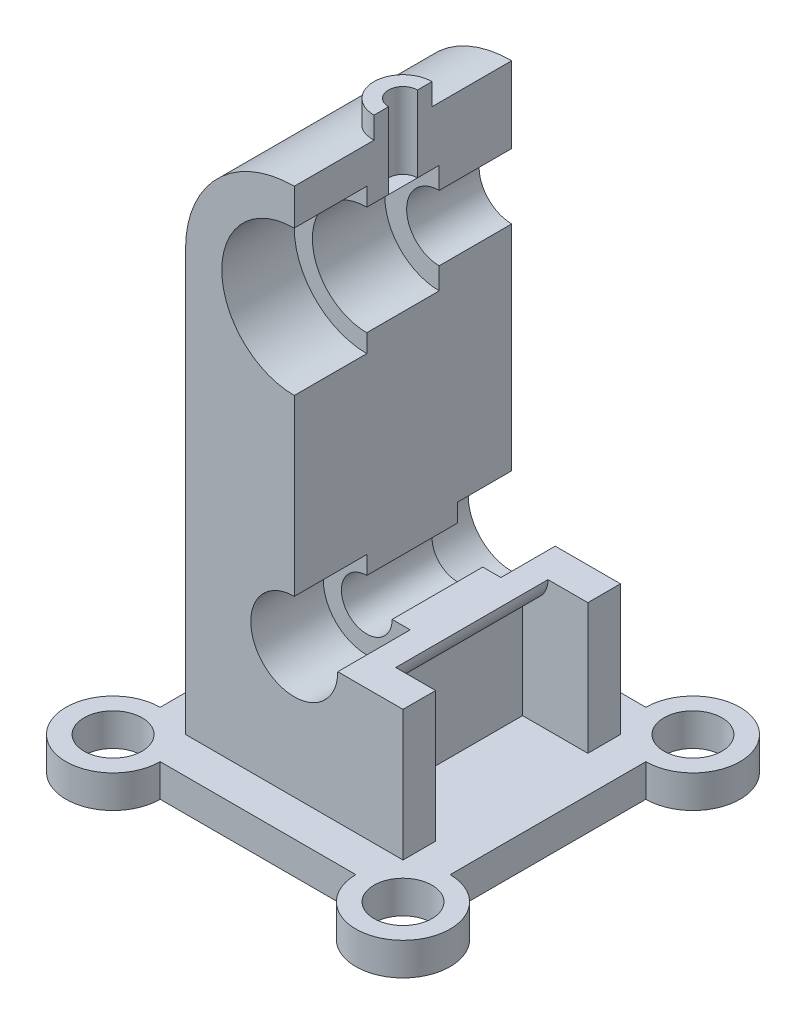
from build123d import *

# Parameters (mm, degrees)
IZIM1_W                          = 60
IZIM1_H                          = 116
Y_KSEKLIK_EKSTR_ZYON1_DEPTH      = 60
IZIM2_R                          = 8
Y_KSEKLIK_EKSTR_ZYON2_DEPTH      = 9
IZIM3_R                          = 30
Y_KSEKLIK_EKSTR_ZYON3_DEPTH      = 60
IZIM4_R                          = 20
KES_EKSTR_ZYON1_DEPTH            = 20
IZIM5_R                          = 15
KES_EKSTR_ZYON2_DEPTH            = 20
IZIM6_R                          = 9
KES_EKSTR_ZYON3_DEPTH            = 20
IZIM7_R                          = 12
KES_EKSTR_ZYON4_DEPTH            = 20
IZIM8_R                          = 7
KES_EKSTR_ZYON5_DEPTH            = 25
IZIM9_R                          = 12
KES_EKSTR_ZYON6_DEPTH            = 15
KES_EKSTR_ZYON8_DEPTH            = 30
IZIM13_W                         = 60
IZIM13_H                         = 30
KES_EKSTR_ZYON9_DEPTH            = 30
IZIM14_R                         = 8
IZIM14_R_2                       = 4
Y_KSEKLIK_EKSTR_ZYON5_DEPTH      = 6
Y_KSEKLIK_EKSTR_ZYON5_DEPTH_BACK = 15
IZIM16_W                         = 8
IZIM16_H                         = 21
KES_EKSTR_ZYON10_DEPTH           = 57
KES_EKSTR_ZYON12_DEPTH           = 15
IZIM18_W                         = 42
IZIM18_H                         = 36
KES_EKSTR_ZYON13_DEPTH           = 18
Y_KSEKLIK_EKSTR_ZYON7_DEPTH      = 42


with BuildPart() as part:
    # Çizim1 → Yükseklik-Ekstrüzyon1 (new body)
    with BuildSketch(Plane(origin=(0, 0, 0), x_dir=(0, 0, -1), z_dir=(1, 0, 0))):
        with Locations((-30, 58)):
            Rectangle(IZIM1_W, IZIM1_H)
    extrude(amount=Y_KSEKLIK_EKSTR_ZYON1_DEPTH)

    # Çizim2 → Yükseklik-Ekstrüzyon2 (add)
    with BuildSketch(Plane(origin=(0, 0, 0), x_dir=(1, 0, 0), z_dir=(0, 1, 0))):
        with BuildLine():
            Line((57, 10), (3, 10))
            ThreePointArc((3, 10), (-19.192388155, 19.192388155), (-10, -3))
            Line((-10, -3), (-10, -57))
            ThreePointArc((-10, -57), (-19.192388155, -79.192388155), (3, -70))
            Line((3, -70), (57, -70))
            ThreePointArc((57, -70), (79.192388155, -79.192388155), (70, -57))
            Line((70, -57), (70, -3))
            ThreePointArc((70, -3), (79.192388155, 19.192388155), (57, 10))
        make_face()
        with Locations((-10, 10)):
            Circle(IZIM2_R, mode=Mode.SUBTRACT)
        with Locations((-10, -70)):
            Circle(IZIM2_R, mode=Mode.SUBTRACT)
        with Locations((70, -70)):
            Circle(IZIM2_R, mode=Mode.SUBTRACT)
        with Locations((70, 10)):
            Circle(IZIM2_R, mode=Mode.SUBTRACT)
    extrude(amount=-Y_KSEKLIK_EKSTR_ZYON2_DEPTH)

    # Çizim3 → Yükseklik-Ekstrüzyon3 (add)
    with BuildSketch(Plane.XY):
        with Locations((30, 116)):
            Circle(IZIM3_R)
    extrude(amount=Y_KSEKLIK_EKSTR_ZYON3_DEPTH)

    # Çizim4 → Kes-Ekstrüzyon1 (cut)
    with BuildSketch(Plane.XY.offset(60)):
        with Locations((30, 116)):
            Circle(IZIM4_R)
    extrude(amount=-KES_EKSTR_ZYON1_DEPTH, mode=Mode.SUBTRACT)

    # Çizim5 → Kes-Ekstrüzyon2 (cut)
    with BuildSketch(Plane.XY.offset(40)):
        with Locations((30, 116)):
            Circle(IZIM5_R)
    extrude(amount=-KES_EKSTR_ZYON2_DEPTH, mode=Mode.SUBTRACT)

    # Çizim6 → Kes-Ekstrüzyon3 (cut)
    with BuildSketch(Plane.XY.offset(20)):
        with Locations((30, 116)):
            Circle(IZIM6_R)
    extrude(amount=-KES_EKSTR_ZYON3_DEPTH, mode=Mode.SUBTRACT)

    # Çizim7 → Kes-Ekstrüzyon4 (cut)
    with BuildSketch(Plane.XY.offset(60)):
        with Locations((30, 36)):
            Circle(IZIM7_R)
    extrude(amount=-KES_EKSTR_ZYON4_DEPTH, mode=Mode.SUBTRACT)

    # Çizim8 → Kes-Ekstrüzyon5 (cut)
    with BuildSketch(Plane.XY.offset(40)):
        with Locations((30, 36)):
            Circle(IZIM8_R)
    extrude(amount=-KES_EKSTR_ZYON5_DEPTH, mode=Mode.SUBTRACT)

    # Çizim9 → Kes-Ekstrüzyon6 (cut)
    with BuildSketch(Plane.XY.offset(15)):
        with Locations((30, 36)):
            Circle(IZIM9_R)
    extrude(amount=-KES_EKSTR_ZYON6_DEPTH, mode=Mode.SUBTRACT)

    # Çizim10 → Kes-Ekstrüzyon8 (cut)
    with BuildSketch(Plane(origin=(60, 0, 0), x_dir=(0, 0, -1), z_dir=(1, 0, 0))):
        Polygon((-60, 116), (-60, 36), (-51, 36), (-9, 36), (0, 36), (0, 116), align=None)
    extrude(amount=-KES_EKSTR_ZYON8_DEPTH, mode=Mode.SUBTRACT)

    # Çizim13 → Kes-Ekstrüzyon9 (cut)
    with BuildSketch(Plane(origin=(30, 0, 0), x_dir=(0, 0, -1), z_dir=(1, 0, 0))):
        with Locations((-30, 131)):
            Rectangle(IZIM13_W, IZIM13_H)
    extrude(amount=KES_EKSTR_ZYON9_DEPTH, mode=Mode.SUBTRACT)

    # Çizim14 → Yükseklik-Ekstrüzyon5 (add, two sides)
    with BuildSketch(Plane(origin=(0, 146, 0), x_dir=(1, 0, 0), z_dir=(0, 1, 0))) as y_kseklik_ekstr_zyon5_sk:
        with Locations((30, -30)):
            Circle(IZIM14_R)
        with Locations((30, -30)):
            Circle(IZIM14_R_2, mode=Mode.SUBTRACT)
    extrude(amount=Y_KSEKLIK_EKSTR_ZYON5_DEPTH)
    extrude(y_kseklik_ekstr_zyon5_sk.sketch, amount=-Y_KSEKLIK_EKSTR_ZYON5_DEPTH_BACK)

    # Çizim16 → Kes-Ekstrüzyon10 (cut)
    with BuildSketch(Plane.XY.offset(46)):
        with Locations((34, 141.5)):
            Rectangle(IZIM16_W, IZIM16_H)
    extrude(amount=-KES_EKSTR_ZYON10_DEPTH, mode=Mode.SUBTRACT)

    # Çizim17 → Kes-Ekstrüzyon12 (cut)
    with BuildSketch(Plane(origin=(0, 146, 0), x_dir=(1, 0, 0), z_dir=(0, 1, 0))):
        with BuildLine():
            Line((30, -26), (30, -34))
            ThreePointArc((30, -34), (26, -30), (30, -26))
        make_face()
    extrude(amount=-KES_EKSTR_ZYON12_DEPTH, mode=Mode.SUBTRACT)

    # Çizim18 → Kes-Ekstrüzyon13 (cut)
    with BuildSketch(Plane(origin=(60, 0, 0), x_dir=(0, 0, -1), z_dir=(1, 0, 0))):
        with Locations((-30, 18)):
            Rectangle(IZIM18_W, IZIM18_H)
    extrude(amount=-KES_EKSTR_ZYON13_DEPTH, mode=Mode.SUBTRACT)

    # Çizim21 → Yükseklik-Ekstrüzyon7 (add)
    with BuildSketch(Plane(origin=(0, 0, 51), x_dir=(-1, 0, 0), z_dir=(0, 0, -1))):
        with BuildLine():
            Line((-42, 29), (-42, 36))
            Line((-42, 36), (-49, 36))
            ThreePointArc((-49, 36), (-46.949747468, 31.050252532), (-42, 29))
        make_face()
    extrude(amount=Y_KSEKLIK_EKSTR_ZYON7_DEPTH)


solid = part.part
